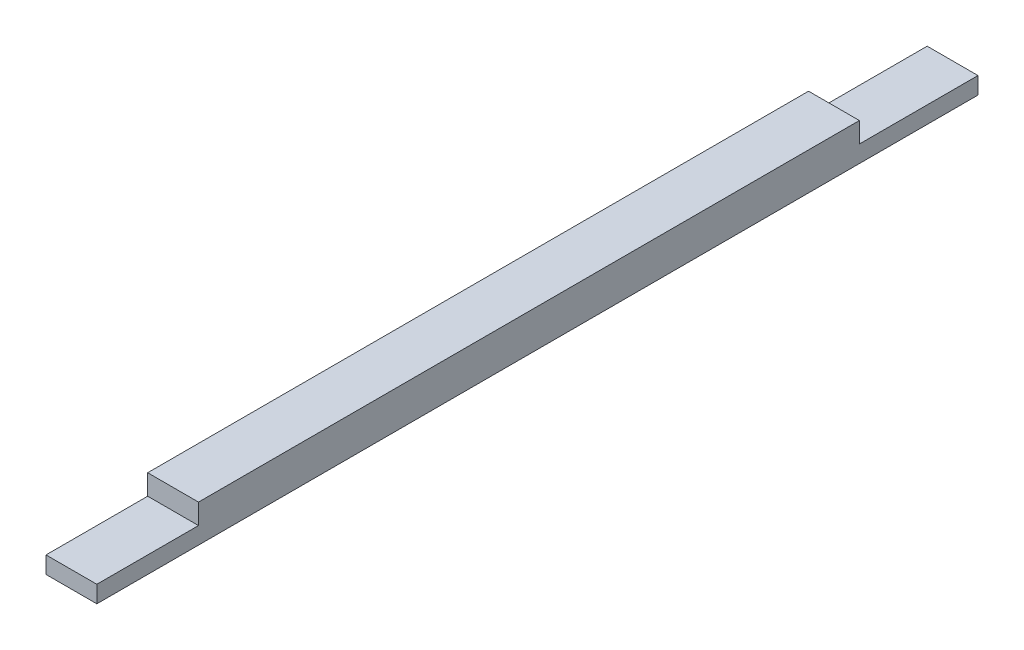
from build123d import *

# Parameters (mm, degrees)
ESQUISSE1_W        = 3
ESQUISSE1_H        = 1
BOSS_EXTRU_1_DEPTH = 52
ESQUISSE2_W        = 3
ESQUISSE2_H        = 39
BOSS_EXTRU_2_DEPTH = 1.2


with BuildPart() as part:
    # Esquisse1 → Boss.-Extru.1 (new body)
    with BuildSketch(Plane.XY):
        with Locations((1.5, -0.5)):
            Rectangle(ESQUISSE1_W, ESQUISSE1_H)
    extrude(amount=BOSS_EXTRU_1_DEPTH)

    # Esquisse2 → Boss.-Extru.2 (add)
    with BuildSketch(Plane(origin=(0, 0, 0), x_dir=(1, 0, 0), z_dir=(0, 1, 0))):
        with Locations((1.5, -26.5)):
            Rectangle(ESQUISSE2_W, ESQUISSE2_H)
    extrude(amount=BOSS_EXTRU_2_DEPTH)


solid = part.part
